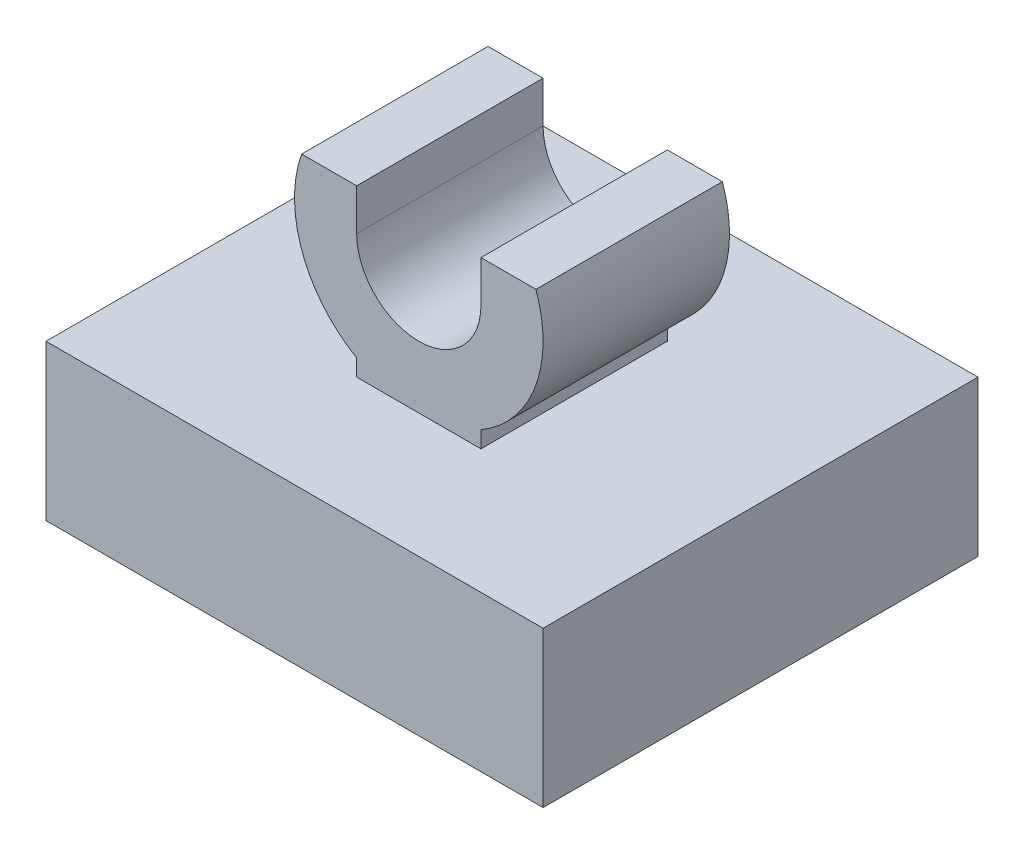
from build123d import *

# Parameters (mm, degrees)
SKETCH1_W           = 10.16
SKETCH1_H           = 3.175
BOSS_EXTRUDE1_DEPTH = 4.445
BOSS_EXTRUDE2_DEPTH = 1.905
SKETCH3_OUTSIDE_W   = 15.162
SKETCH3_OUTSIDE_H   = 13.892
SKETCH3_OUTSIDE_W_2 = 10.16
SKETCH3_OUTSIDE_H_2 = 8.89
SKETCH3_OUTSIDE_W_3 = 5.08
SKETCH3_OUTSIDE_H_3 = 5.08
CUT_EXTRUDE1_DEPTH  = 1.905


with BuildPart() as part:
    # Sketch1 → Boss-Extrude1 (new body, symmetric)
    with BuildSketch(Plane.XY):
        with Locations((0, -1.5875)):
            Rectangle(SKETCH1_W, SKETCH1_H)
    extrude(amount=BOSS_EXTRUDE1_DEPTH, both=True)

    # Sketch2 → Boss-Extrude2 (add, symmetric)
    with BuildSketch(Plane.XY):
        with BuildLine():
            Line((-1.27, 2.54), (-1.27, 3.386666667))
            Line((-1.27, 3.386666667), (-2.394734966, 3.386666667))
            ThreePointArc((-2.394734966, 3.386666667), (-2.382785125, 1.660264217), (-1.27, 0.340295474))
            Line((-1.27, 0.340295474), (-1.27, 0))
            Line((-1.27, 0), (1.27, 0))
            Line((1.27, 0), (1.27, 0.340295474))
            ThreePointArc((1.27, 0.340295474), (2.382785125, 1.660264217), (2.394734966, 3.386666667))
            Line((2.394734966, 3.386666667), (1.27, 3.386666667))
            Line((1.27, 3.386666667), (1.27, 2.54))
            ThreePointArc((1.27, 2.54), (0, 1.27), (-1.27, 2.54))
        make_face()
    extrude(amount=BOSS_EXTRUDE2_DEPTH, both=True)

    # Sketch3 outside → Cut-Extrude1 (cut)
    with BuildSketch(Plane.XZ.offset(3.175)):
        Rectangle(SKETCH3_OUTSIDE_W, SKETCH3_OUTSIDE_H)
        Rectangle(SKETCH3_OUTSIDE_W_2, SKETCH3_OUTSIDE_H_2, mode=Mode.SUBTRACT)
        Rectangle(SKETCH3_OUTSIDE_W_3, SKETCH3_OUTSIDE_H_3)
    extrude(amount=-CUT_EXTRUDE1_DEPTH, mode=Mode.SUBTRACT)


solid = part.part
